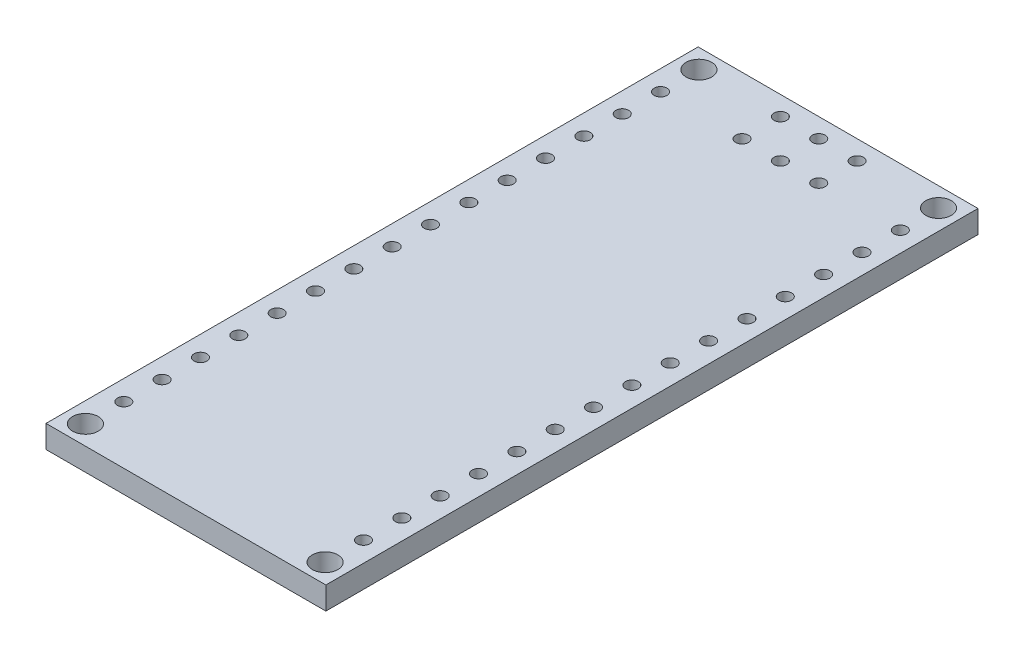
from build123d import *

# Parameters (mm, degrees)
SKETCH1_W           = 18.54
SKETCH1_H           = 43.2
BOSS_EXTRUDE1_DEPTH = 1.5
SKETCH2_R           = 0.846666667
SKETCH2_R_2         = 0.423333333
CUT_EXTRUDE1_DEPTH  = 2.5


with BuildPart() as part:
    # Sketch1 → Boss-Extrude1 (new body)
    with BuildSketch(Plane(origin=(0, 0, 0), x_dir=(1, 0, 0), z_dir=(0, 1, 0))):
        Rectangle(SKETCH1_W, SKETCH1_H)
    extrude(amount=BOSS_EXTRUDE1_DEPTH)

    # Sketch2 → Cut-Extrude1 (cut, through all)
    with BuildSketch(Plane(origin=(0, 1.5, 0), x_dir=(1, 0, 0), z_dir=(0, 1, 0))):
        with Locations((7.9375, 20.32)):
            Circle(SKETCH2_R)
        with Locations((7.9375, -20.32)):
            Circle(SKETCH2_R)
        with Locations((-7.9375, -20.32)):
            Circle(SKETCH2_R)
        with Locations((-7.9375, 20.32)):
            Circle(SKETCH2_R)
        with Locations((-7.9375, -17.78)):
            Circle(SKETCH2_R_2)
        with Locations((-7.9375, -15.24)):
            Circle(SKETCH2_R_2)
        with Locations((-7.9375, -12.7)):
            Circle(SKETCH2_R_2)
        with Locations((-7.9375, -10.16)):
            Circle(SKETCH2_R_2)
        with Locations((-7.9375, -7.62)):
            Circle(SKETCH2_R_2)
        with Locations((-7.9375, -5.08)):
            Circle(SKETCH2_R_2)
        with Locations((-7.9375, -2.54)):
            Circle(SKETCH2_R_2)
        with Locations((-7.9375, 0)):
            Circle(SKETCH2_R_2)
        with Locations((-7.9375, 2.54)):
            Circle(SKETCH2_R_2)
        with Locations((-7.9375, 5.08)):
            Circle(SKETCH2_R_2)
        with Locations((-7.9375, 7.62)):
            Circle(SKETCH2_R_2)
        with Locations((-7.9375, 10.16)):
            Circle(SKETCH2_R_2)
        with Locations((-7.9375, 12.7)):
            Circle(SKETCH2_R_2)
        with Locations((-7.9375, 15.24)):
            Circle(SKETCH2_R_2)
        with Locations((-7.9375, 17.78)):
            Circle(SKETCH2_R_2)
        with Locations((7.9425, -15.24)):
            Circle(SKETCH2_R_2)
        with Locations((7.9425, -12.7)):
            Circle(SKETCH2_R_2)
        with Locations((7.9425, -10.16)):
            Circle(SKETCH2_R_2)
        with Locations((7.9425, -7.62)):
            Circle(SKETCH2_R_2)
        with Locations((7.9425, -5.08)):
            Circle(SKETCH2_R_2)
        with Locations((7.9425, -2.54)):
            Circle(SKETCH2_R_2)
        with Locations((7.9425, 0)):
            Circle(SKETCH2_R_2)
        with Locations((7.9425, 2.54)):
            Circle(SKETCH2_R_2)
        with Locations((7.9425, 5.08)):
            Circle(SKETCH2_R_2)
        with Locations((7.9425, 7.62)):
            Circle(SKETCH2_R_2)
        with Locations((7.9425, 10.16)):
            Circle(SKETCH2_R_2)
        with Locations((7.9425, 12.7)):
            Circle(SKETCH2_R_2)
        with Locations((7.9425, 15.24)):
            Circle(SKETCH2_R_2)
        with Locations((7.9425, 17.78)):
            Circle(SKETCH2_R_2)
        with Locations((7.9425, -17.78)):
            Circle(SKETCH2_R_2)
        with Locations((0, 20.32)):
            Circle(SKETCH2_R_2)
        with Locations((-2.54, 20.32)):
            Circle(SKETCH2_R_2)
        with Locations((2.54, 20.32)):
            Circle(SKETCH2_R_2)
        with Locations((-2.54, 17.78)):
            Circle(SKETCH2_R_2)
        with Locations((0, 17.78)):
            Circle(SKETCH2_R_2)
        with Locations((2.54, 17.78)):
            Circle(SKETCH2_R_2)
    extrude(amount=-CUT_EXTRUDE1_DEPTH, mode=Mode.SUBTRACT)


solid = part.part
